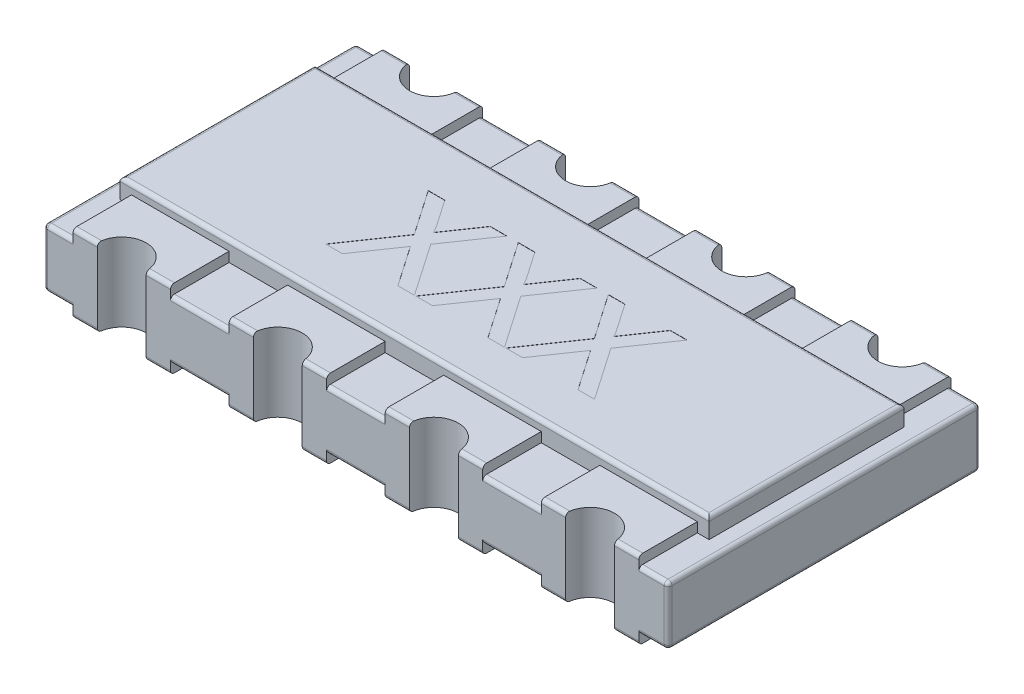
from build123d import *

# Parameters (mm, degrees)
BOSS_EXTRUDE1_START   = 0.05
BOSS_EXTRUDE1_DEPTH   = 0.3
FILLET1_R             = 0.02
BOSS_EXTRUDE2_DEPTH   = 0.4
BOSS_EXTRUDE2_2_DEPTH = 0.4
BOSS_EXTRUDE2_3_DEPTH = 0.4
BOSS_EXTRUDE2_4_DEPTH = 0.4
BOSS_EXTRUDE2_5_DEPTH = 0.4
BOSS_EXTRUDE2_6_DEPTH = 0.4
BOSS_EXTRUDE2_7_DEPTH = 0.4
BOSS_EXTRUDE2_8_DEPTH = 0.4
SKETCH3_W             = 3.02
SKETCH3_H             = 1
BOSS_EXTRUDE3_DEPTH   = 0.1
FILLET2_R             = 0.02
CUT_EXTRUDE1_DEPTH    = 0.001


with BuildPart() as part:
    # Sketch1 → Boss-Extrude1 (new body)
    with BuildSketch(Plane(origin=(0, 0, 0), x_dir=(1, 0, 0), z_dir=(0, 1, 0)).offset(BOSS_EXTRUDE1_START)):
        with BuildLine():
            Line((-1.33, -0.8), (-1.6, -0.8))
            Line((-1.6, -0.8), (-1.6, 0.8))
            Line((-1.6, 0.8), (-1.33, 0.8))
            ThreePointArc((-1.33, 0.8), (-1.2, 0.67), (-1.07, 0.8))
            Line((-1.07, 0.8), (-0.53, 0.8))
            ThreePointArc((-0.53, 0.8), (-0.4, 0.67), (-0.27, 0.8))
            Line((-0.27, 0.8), (0.27, 0.8))
            ThreePointArc((0.27, 0.8), (0.4, 0.67), (0.53, 0.8))
            Line((0.53, 0.8), (1.07, 0.8))
            ThreePointArc((1.07, 0.8), (1.2, 0.67), (1.33, 0.8))
            Line((1.33, 0.8), (1.6, 0.8))
            Line((1.6, 0.8), (1.6, -0.8))
            Line((1.6, -0.8), (1.33, -0.8))
            ThreePointArc((1.33, -0.8), (1.2, -0.67), (1.07, -0.8))
            Line((1.07, -0.8), (0.53, -0.8))
            ThreePointArc((0.53, -0.8), (0.4, -0.67), (0.27, -0.8))
            Line((0.27, -0.8), (-0.27, -0.8))
            ThreePointArc((-0.27, -0.8), (-0.4, -0.67), (-0.53, -0.8))
            Line((-0.53, -0.8), (-1.07, -0.8))
            ThreePointArc((-1.07, -0.8), (-1.2, -0.67), (-1.33, -0.8))
        make_face()
    extrude(amount=BOSS_EXTRUDE1_DEPTH)

    # Fillet1
    fillet1_edges = [part.edges().sort_by_distance(p)[0] for p in [
        (-1.465, 0.35, 0.8),
        (-1.2, 0.35, 0.67),
        (-0.8, 0.35, 0.8),
        (-1.2, 0.05, -0.67),
        (-0.8, 0.05, -0.8),
        (-0.4, 0.05, -0.67),
        (0, 0.05, -0.8),
        (0.4, 0.05, -0.67),
        (-0.4, 0.35, 0.67),
        (0.8, 0.05, -0.8),
        (1.2, 0.05, -0.67),
        (1.465, 0.05, -0.8),
        (1.6, 0.05, 0),
        (1.465, 0.05, 0.8),
        (1.2, 0.05, 0.67),
        (0.8, 0.05, 0.8),
        (0, 0.35, 0.8),
        (0.4, 0.05, 0.67),
        (0, 0.05, 0.8),
        (-0.4, 0.05, 0.67),
        (-0.8, 0.05, 0.8),
        (-1.2, 0.05, 0.67),
        (-1.465, 0.05, 0.8),
        (-1.6, 0.05, 0),
        (-1.465, 0.05, -0.8),
        (0.4, 0.35, 0.67),
        (0.8, 0.35, 0.8),
        (1.2, 0.35, 0.67),
        (1.6, 0.2, -0.8),
        (1.6, 0.2, 0.8),
        (-1.6, 0.2, 0.8),
        (-1.6, 0.2, -0.8),
        (1.465, 0.35, 0.8),
        (1.6, 0.35, 0),
        (-1.465, 0.35, -0.8),
        (1.465, 0.35, -0.8),
        (1.2, 0.35, -0.67),
        (0.8, 0.35, -0.8),
        (0.4, 0.35, -0.67),
        (0, 0.35, -0.8),
        (-0.4, 0.35, -0.67),
        (-0.8, 0.35, -0.8),
        (-1.2, 0.35, -0.67),
        (-1.6, 0.35, 0),
    ]]
    fillet(fillet1_edges, radius=FILLET1_R)



with BuildPart() as body_2:
    # Sketch2 → Boss-Extrude2 (new body)
    with BuildSketch(Plane(origin=(0, 0, 0), x_dir=(1, 0, 0), z_dir=(0, 1, 0))):
        with BuildLine():
            Line((-1.075, 0.8), (-0.95, 0.8))
            Line((-0.95, 0.8), (-0.95, 0.5))
            Line((-0.95, 0.5), (-1.45, 0.5))
            Line((-1.45, 0.5), (-1.45, 0.8))
            Line((-1.45, 0.8), (-1.325, 0.8))
            ThreePointArc((-1.325, 0.8), (-1.2, 0.675), (-1.075, 0.8))
        make_face()
    extrude(amount=BOSS_EXTRUDE2_DEPTH)


with BuildPart() as body_3:
    # Sketch2 → Boss-Extrude2 2 (new body)
    with BuildSketch(Plane(origin=(0, 0, 0), x_dir=(1, 0, 0), z_dir=(0, 1, 0))):
        with BuildLine():
            Line((-0.275, 0.8), (-0.15, 0.8))
            Line((-0.15, 0.8), (-0.15, 0.5))
            Line((-0.15, 0.5), (-0.65, 0.5))
            Line((-0.65, 0.5), (-0.65, 0.8))
            Line((-0.65, 0.8), (-0.525, 0.8))
            ThreePointArc((-0.525, 0.8), (-0.4, 0.675), (-0.275, 0.8))
        make_face()
    extrude(amount=BOSS_EXTRUDE2_2_DEPTH)


with BuildPart() as body_4:
    # Sketch2 → Boss-Extrude2 3 (new body)
    with BuildSketch(Plane(origin=(0, 0, 0), x_dir=(1, 0, 0), z_dir=(0, 1, 0))):
        with BuildLine():
            Line((0.525, 0.8), (0.65, 0.8))
            Line((0.65, 0.8), (0.65, 0.5))
            Line((0.65, 0.5), (0.15, 0.5))
            Line((0.15, 0.5), (0.15, 0.8))
            Line((0.15, 0.8), (0.275, 0.8))
            ThreePointArc((0.275, 0.8), (0.4, 0.675), (0.525, 0.8))
        make_face()
    extrude(amount=BOSS_EXTRUDE2_3_DEPTH)


with BuildPart() as body_5:
    # Sketch2 → Boss-Extrude2 4 (new body)
    with BuildSketch(Plane(origin=(0, 0, 0), x_dir=(1, 0, 0), z_dir=(0, 1, 0))):
        with BuildLine():
            Line((1.325, 0.8), (1.45, 0.8))
            Line((1.45, 0.8), (1.45, 0.5))
            Line((1.45, 0.5), (0.95, 0.5))
            Line((0.95, 0.5), (0.95, 0.8))
            Line((0.95, 0.8), (1.075, 0.8))
            ThreePointArc((1.075, 0.8), (1.2, 0.675), (1.325, 0.8))
        make_face()
    extrude(amount=BOSS_EXTRUDE2_4_DEPTH)


with BuildPart() as body_6:
    # Sketch2 → Boss-Extrude2 5 (new body)
    with BuildSketch(Plane(origin=(0, 0, 0), x_dir=(1, 0, 0), z_dir=(0, 1, 0))):
        with BuildLine():
            Line((-1.075, -0.8), (-0.95, -0.8))
            Line((-0.95, -0.8), (-0.95, -0.5))
            Line((-0.95, -0.5), (-1.45, -0.5))
            Line((-1.45, -0.5), (-1.45, -0.8))
            Line((-1.45, -0.8), (-1.325, -0.8))
            ThreePointArc((-1.325, -0.8), (-1.2, -0.675), (-1.075, -0.8))
        make_face()
    extrude(amount=BOSS_EXTRUDE2_5_DEPTH)


with BuildPart() as body_7:
    # Sketch2 → Boss-Extrude2 6 (new body)
    with BuildSketch(Plane(origin=(0, 0, 0), x_dir=(1, 0, 0), z_dir=(0, 1, 0))):
        with BuildLine():
            Line((1.45, -0.5), (1.45, -0.8))
            Line((1.45, -0.8), (1.325, -0.8))
            ThreePointArc((1.325, -0.8), (1.2, -0.675), (1.075, -0.8))
            Line((1.075, -0.8), (0.95, -0.8))
            Line((0.95, -0.8), (0.95, -0.5))
            Line((0.95, -0.5), (1.45, -0.5))
        make_face()
    extrude(amount=BOSS_EXTRUDE2_6_DEPTH)


with BuildPart() as body_8:
    # Sketch2 → Boss-Extrude2 7 (new body)
    with BuildSketch(Plane(origin=(0, 0, 0), x_dir=(1, 0, 0), z_dir=(0, 1, 0))):
        with BuildLine():
            Line((0.65, -0.5), (0.65, -0.8))
            Line((0.65, -0.8), (0.525, -0.8))
            ThreePointArc((0.525, -0.8), (0.4, -0.675), (0.275, -0.8))
            Line((0.275, -0.8), (0.15, -0.8))
            Line((0.15, -0.8), (0.15, -0.5))
            Line((0.15, -0.5), (0.65, -0.5))
        make_face()
    extrude(amount=BOSS_EXTRUDE2_7_DEPTH)


with BuildPart() as body_9:
    # Sketch2 → Boss-Extrude2 8 (new body)
    with BuildSketch(Plane(origin=(0, 0, 0), x_dir=(1, 0, 0), z_dir=(0, 1, 0))):
        with BuildLine():
            Line((-0.15, -0.5), (-0.15, -0.8))
            Line((-0.15, -0.8), (-0.275, -0.8))
            ThreePointArc((-0.275, -0.8), (-0.4, -0.675), (-0.525, -0.8))
            Line((-0.525, -0.8), (-0.65, -0.8))
            Line((-0.65, -0.8), (-0.65, -0.5))
            Line((-0.65, -0.5), (-0.15, -0.5))
        make_face()
    extrude(amount=BOSS_EXTRUDE2_8_DEPTH)


with BuildPart() as part_1:
    add(part.part)

    add(body_2.part)  # Boss-Extrude3 merges body 2

    add(body_3.part)  # Boss-Extrude3 merges body 3

    add(body_4.part)  # Boss-Extrude3 merges body 4

    add(body_5.part)  # Boss-Extrude3 merges body 5

    add(body_6.part)  # Boss-Extrude3 merges body 6

    add(body_7.part)  # Boss-Extrude3 merges body 7

    add(body_8.part)  # Boss-Extrude3 merges body 8

    add(body_9.part)  # Boss-Extrude3 merges body 9
    # Sketch3 → Boss-Extrude3 (add)
    with BuildSketch(Plane(origin=(0, 0.35, 0), x_dir=(1, 0, 0), z_dir=(0, 1, 0))):
        Rectangle(SKETCH3_W, SKETCH3_H)
    extrude(amount=BOSS_EXTRUDE3_DEPTH)

    # Fillet2
    fillet2_edges = [part_1.edges().sort_by_distance(p)[0] for p in [
        (-1.51, 0.45, 0),
        (0, 0.45, 0.5),
        (1.51, 0.45, 0),
        (0, 0.45, -0.5),
        (-0.2125, 0, 0.8),
        (-0.4, 0, 0.5),
        (-0.5875, 0, 0.8),
        (-0.2125, 0.4, 0.8),
        (-0.5875, 0.4, 0.8),
        (-1.2, 0, -0.5),
        (-1.0125, 0, -0.8),
        (-1.3875, 0, -0.8),
        (-1.0125, 0.4, -0.8),
        (-1.3875, 0.4, -0.8),
        (-1.0125, 0, 0.8),
        (-1.2, 0, 0.5),
        (-1.3875, 0, 0.8),
        (-1.0125, 0.4, 0.8),
        (-1.3875, 0.4, 0.8),
        (1.3875, 0, 0.8),
        (1.2, 0, 0.5),
        (1.0125, 0, 0.8),
        (1.3875, 0.4, 0.8),
        (1.0125, 0.4, 0.8),
        (-0.4, 0, -0.5),
        (-0.2125, 0, -0.8),
        (-0.5875, 0, -0.8),
        (-0.2125, 0.4, -0.8),
        (-0.5875, 0.4, -0.8),
        (0.4, 0, -0.5),
        (0.5875, 0, -0.8),
        (0.2125, 0, -0.8),
        (0.5875, 0.4, -0.8),
        (0.2125, 0.4, -0.8),
        (1.2, 0, -0.5),
        (1.3875, 0, -0.8),
        (1.0125, 0, -0.8),
        (1.3875, 0.4, -0.8),
        (1.0125, 0.4, -0.8),
        (0.5875, 0, 0.8),
        (0.4, 0, 0.5),
        (0.2125, 0, 0.8),
        (0.5875, 0.4, 0.8),
        (0.2125, 0.4, 0.8),
    ]]
    fillet(fillet2_edges, radius=FILLET2_R)

    # Sketch4 → Cut-Extrude1 (cut)
    with BuildSketch(Plane(origin=(0, 0.45, 0), x_dir=(1, 0, 0), z_dir=(0, 1, 0))):
        with BuildLine():
            Line((-0.684613185, -0.270397793), (-0.499817512, -0.001367344))
            Line((-0.499817512, -0.001367344), (-0.658972159, 0.229602207))
            Line((-0.658972159, 0.229602207), (-0.574036262, 0.229602207))
            Line((-0.574036262, 0.229602207), (-0.486796679, 0.102999643))
            add(Edge.make_bspline(
                [(-0.486796679, 0.102999643), (-0.484654741, 0.099831542), (-0.480635323, 0.093886495), (-0.4750479, 0.085453847), (-0.47049799, 0.077969971), (-0.466694312, 0.071543204), (-0.463925749, 0.066068669), (-0.461903541, 0.061647416), (-0.460866088, 0.058143591), (-0.460858287, 0.056128113), (-0.460855172, 0.055323361)],
                knots=[0, 0, 0, 0, 1.1473e-05, 2.153e-05, 3.0342e-05, 3.7746e-05, 4.3928e-05, 4.8728e-05, 5.2348e-05, 5.4754e-05, 5.4754e-05, 5.4754e-05, 5.4754e-05], degree=3))
            add(Edge.make_bspline(
                [(-0.460855172, 0.055323361), (-0.458716646, 0.058427111), (-0.454029835, 0.065229315), (-0.446468404, 0.076292245), (-0.437730848, 0.089052693), (-0.431510163, 0.098093126), (-0.428202929, 0.102899483)],
                knots=[0, 0, 0, 0, 1.1307e-05, 2.4782e-05, 4.02e-05, 5.7703e-05, 5.7703e-05, 5.7703e-05, 5.7703e-05], degree=3))
            Line((-0.428202929, 0.102899483), (-0.341263826, 0.229602207))
            Line((-0.341263826, 0.229602207), (-0.255126005, 0.229602207))
            Line((-0.255126005, 0.229602207), (-0.414280653, -0.002168626))
            Line((-0.414280653, -0.002168626), (-0.22948498, -0.270397793))
            Line((-0.22948498, -0.270397793), (-0.314521037, -0.270397793))
            Line((-0.314521037, -0.270397793), (-0.436215749, -0.093715101))
            add(Edge.make_bspline(
                [(-0.436215749, -0.093715101), (-0.439693348, -0.088710799), (-0.446569037, -0.078816609), (-0.453381673, -0.0688789), (-0.456748602, -0.063967504)],
                knots=[0, 0, 0, 0, 1.8282e-05, 3.6146e-05, 3.6146e-05, 3.6146e-05, 3.6146e-05], degree=3))
            add(Edge.make_bspline(
                [(-0.456748602, -0.063967504), (-0.459312408, -0.067711602), (-0.464031996, -0.074603932), (-0.470601464, -0.083989124), (-0.475785594, -0.091763536), (-0.478913506, -0.096321922), (-0.480286262, -0.098322472)],
                knots=[0, 0, 0, 0, 1.3613e-05, 2.506e-05, 3.4366e-05, 4.1645e-05, 4.1645e-05, 4.1645e-05, 4.1645e-05], degree=3))
            Line((-0.480286262, -0.098322472), (-0.598575525, -0.270397793))
            Line((-0.598575525, -0.270397793), (-0.684613185, -0.270397793))
        make_face()
        with BuildLine():
            Line((-0.223074723, -0.270397793), (-0.03827905, -0.001367344))
            Line((-0.03827905, -0.001367344), (-0.197433698, 0.229602207))
            Line((-0.197433698, 0.229602207), (-0.1124978, 0.229602207))
            Line((-0.1124978, 0.229602207), (-0.025258217, 0.102999643))
            add(Edge.make_bspline(
                [(-0.025258217, 0.102999643), (-0.023116279, 0.099831542), (-0.019096862, 0.093886495), (-0.013509439, 0.085453847), (-0.008959528, 0.077969971), (-0.005155851, 0.071543204), (-0.002387288, 0.066068669), (-0.000365079, 0.061647416), (0.000672374, 0.058143591), (0.000680175, 0.056128113), (0.000683289, 0.055323361)],
                knots=[0, 0, 0, 0, 1.1473e-05, 2.153e-05, 3.0342e-05, 3.7746e-05, 4.3928e-05, 4.8728e-05, 5.2348e-05, 5.4754e-05, 5.4754e-05, 5.4754e-05, 5.4754e-05], degree=3))
            add(Edge.make_bspline(
                [(0.000683289, 0.055323361), (0.002821816, 0.058427111), (0.007508626, 0.065229315), (0.015070057, 0.076292245), (0.023807613, 0.089052693), (0.030028298, 0.098093126), (0.033335533, 0.102899483)],
                knots=[0, 0, 0, 0, 1.1307e-05, 2.4782e-05, 4.02e-05, 5.7703e-05, 5.7703e-05, 5.7703e-05, 5.7703e-05], degree=3))
            Line((0.033335533, 0.102899483), (0.120274636, 0.229602207))
            Line((0.120274636, 0.229602207), (0.206412456, 0.229602207))
            Line((0.206412456, 0.229602207), (0.047257809, -0.002168626))
            Line((0.047257809, -0.002168626), (0.232053482, -0.270397793))
            Line((0.232053482, -0.270397793), (0.147017424, -0.270397793))
            Line((0.147017424, -0.270397793), (0.025322713, -0.093715101))
            add(Edge.make_bspline(
                [(0.025322713, -0.093715101), (0.021845114, -0.088710799), (0.014969425, -0.078816609), (0.008156788, -0.0688789), (0.00478986, -0.063967504)],
                knots=[0, 0, 0, 0, 1.8282e-05, 3.6146e-05, 3.6146e-05, 3.6146e-05, 3.6146e-05], degree=3))
            add(Edge.make_bspline(
                [(0.00478986, -0.063967504), (0.002226054, -0.067711602), (-0.002493534, -0.074603932), (-0.009063002, -0.083989124), (-0.014247132, -0.091763536), (-0.017375045, -0.096321922), (-0.0187478, -0.098322472)],
                knots=[0, 0, 0, 0, 1.3613e-05, 2.506e-05, 3.4366e-05, 4.1645e-05, 4.1645e-05, 4.1645e-05, 4.1645e-05], degree=3))
            Line((-0.0187478, -0.098322472), (-0.137037063, -0.270397793))
            Line((-0.137037063, -0.270397793), (-0.223074723, -0.270397793))
        make_face()
        with BuildLine():
            Line((0.238463738, -0.270397793), (0.423259411, -0.001367344))
            Line((0.423259411, -0.001367344), (0.264104764, 0.229602207))
            Line((0.264104764, 0.229602207), (0.349040661, 0.229602207))
            Line((0.349040661, 0.229602207), (0.436280245, 0.102999643))
            add(Edge.make_bspline(
                [(0.436280245, 0.102999643), (0.438422182, 0.099831542), (0.4424416, 0.093886495), (0.448029023, 0.085453847), (0.452578934, 0.077969971), (0.456382611, 0.071543204), (0.459151174, 0.066068669), (0.461173383, 0.061647416), (0.462210835, 0.058143591), (0.462218636, 0.056128113), (0.462221751, 0.055323361)],
                knots=[0, 0, 0, 0, 1.1473e-05, 2.153e-05, 3.0342e-05, 3.7746e-05, 4.3928e-05, 4.8728e-05, 5.2348e-05, 5.4754e-05, 5.4754e-05, 5.4754e-05, 5.4754e-05], degree=3))
            add(Edge.make_bspline(
                [(0.462221751, 0.055323361), (0.464360277, 0.058427111), (0.469047088, 0.065229315), (0.476608519, 0.076292245), (0.485346075, 0.089052693), (0.49156676, 0.098093126), (0.494873995, 0.102899483)],
                knots=[0, 0, 0, 0, 1.1307e-05, 2.4782e-05, 4.02e-05, 5.7703e-05, 5.7703e-05, 5.7703e-05, 5.7703e-05], degree=3))
            Line((0.494873995, 0.102899483), (0.581813097, 0.229602207))
            Line((0.581813097, 0.229602207), (0.667950918, 0.229602207))
            Line((0.667950918, 0.229602207), (0.50879627, -0.002168626))
            Line((0.50879627, -0.002168626), (0.693591943, -0.270397793))
            Line((0.693591943, -0.270397793), (0.608555886, -0.270397793))
            Line((0.608555886, -0.270397793), (0.486861174, -0.093715101))
            add(Edge.make_bspline(
                [(0.486861174, -0.093715101), (0.483383575, -0.088710799), (0.476507886, -0.078816609), (0.46969525, -0.0688789), (0.466328321, -0.063967504)],
                knots=[0, 0, 0, 0, 1.8282e-05, 3.6146e-05, 3.6146e-05, 3.6146e-05, 3.6146e-05], degree=3))
            add(Edge.make_bspline(
                [(0.466328321, -0.063967504), (0.463764515, -0.067711602), (0.459044927, -0.074603932), (0.452475459, -0.083989124), (0.44729133, -0.091763536), (0.444163417, -0.096321922), (0.442790661, -0.098322472)],
                knots=[0, 0, 0, 0, 1.3613e-05, 2.506e-05, 3.4366e-05, 4.1645e-05, 4.1645e-05, 4.1645e-05, 4.1645e-05], degree=3))
            Line((0.442790661, -0.098322472), (0.324501398, -0.270397793))
            Line((0.324501398, -0.270397793), (0.238463738, -0.270397793))
        make_face()
    extrude(amount=-CUT_EXTRUDE1_DEPTH, mode=Mode.SUBTRACT)


solid = part_1.part
